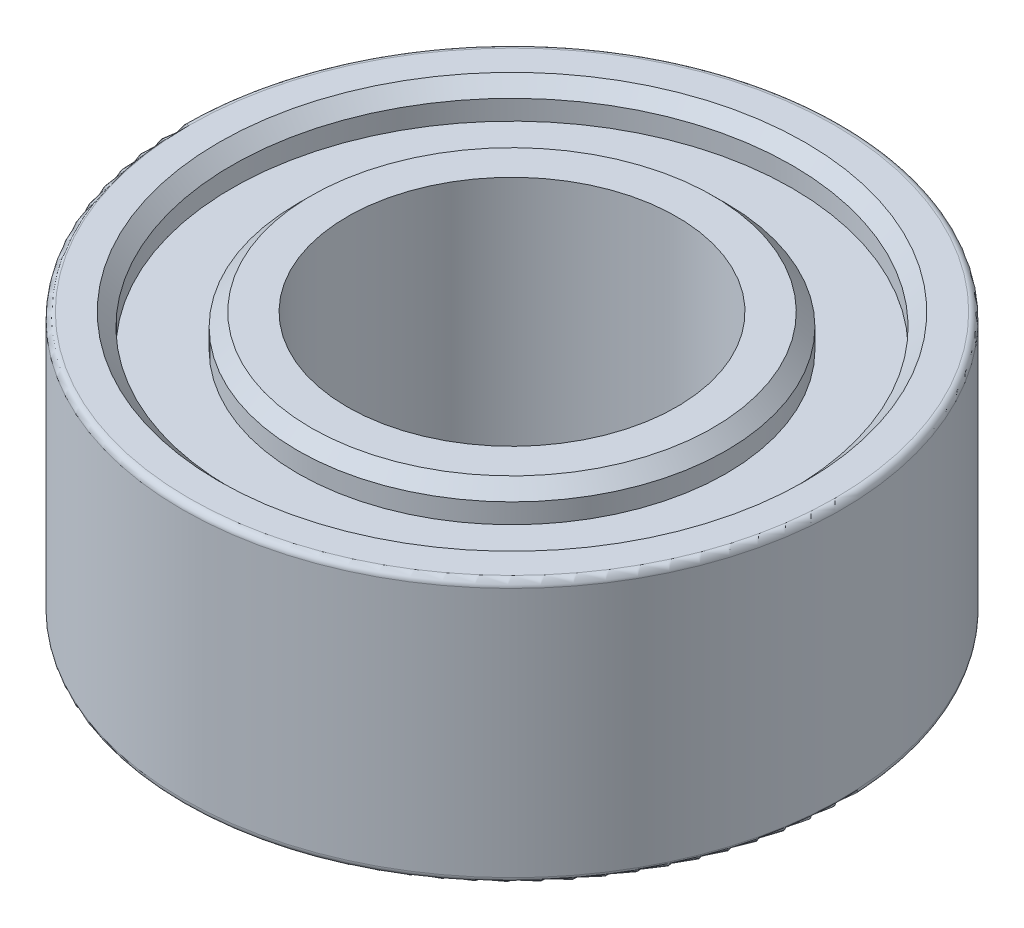
from build123d import *

# Parameters (mm, degrees)
SKETCH2_R           = 5
SKETCH2_R_2         = 2.5
BOSS_EXTRUDE1_DEPTH = 2
SKETCH3_R           = 4.25
SKETCH3_R_2         = 3.25
CUT_EXTRUDE1_DEPTH  = 0.5
CHAMFER1_SIZE       = 0.2
FILLET1_R           = 0.1


with BuildPart() as part:
    # Sketch2 → Boss-Extrude1 (new body, symmetric)
    with BuildSketch(Plane(origin=(0, 0, 0), x_dir=(1, 0, 0), z_dir=(0, 1, 0))):
        Circle(SKETCH2_R)
        Circle(SKETCH2_R_2, mode=Mode.SUBTRACT)
    extrude(amount=BOSS_EXTRUDE1_DEPTH, both=True)

    # Sketch3 → Cut-Extrude1 (cut)
    with BuildSketch(Plane(origin=(0, 2, 0), x_dir=(1, 0, 0), z_dir=(0, 1, 0))):
        Circle(SKETCH3_R)
        Circle(SKETCH3_R_2, mode=Mode.SUBTRACT)
    cut_extrude1 = extrude(amount=-CUT_EXTRUDE1_DEPTH, mode=Mode.SUBTRACT)

    # Mirror1: Cut-Extrude1 across plane
    add(cut_extrude1.mirror(Plane.ZX), mode=Mode.SUBTRACT)

    # Chamfer1
    chamfer1_edges = [part.edges().sort_by_distance(p)[0] for p in [
        (-4.25, 2, 0),
        (-3.25, 2, 0),
        (-3.25, -2, 0),
        (-4.25, -2, 0),
    ]]
    chamfer(chamfer1_edges, length=CHAMFER1_SIZE)

    # Fillet1
    fillet1_edges = [part.edges().sort_by_distance(p)[0] for p in [
        (-5, -2, 0),
        (-5, 2, 0),
    ]]
    fillet(fillet1_edges, radius=FILLET1_R)


solid = part.part
